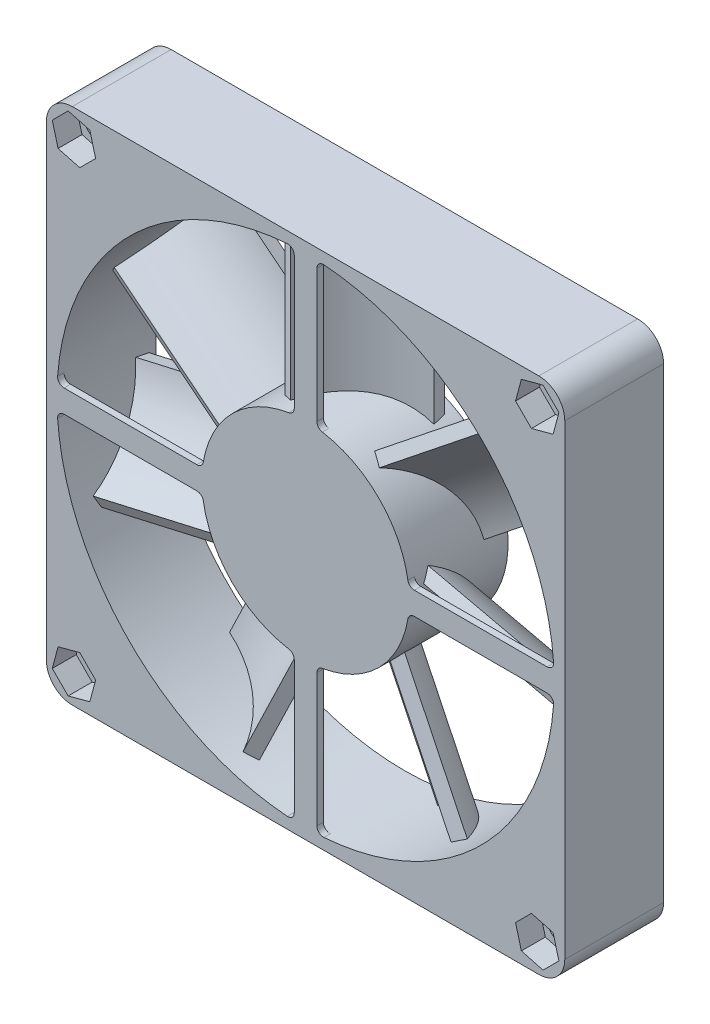
from build123d import *

# Parameters (mm, degrees)
SKETCH1_R           = 38.375
SKETCH1_R_2         = 2.11
BOSS_EXTRUDE1_DEPTH = 15.25
BOSS_EXTRUDE2_DEPTH = 1
CIRPATTERN1_COUNT   = 4
SKETCH4_R           = 16
BOSS_EXTRUDE3_DEPTH = 14.25
EXTRUDE_THIN1_DEPTH = 37
CIRPATTERN2_COUNT   = 7
CUT_EXTRUDE1_DEPTH  = 3.7
CUT_EXTRUDE2_DEPTH  = 3.7
CIRPATTERN3_COUNT   = 4


with BuildPart() as part:
    # Sketch1 → Boss-Extrude1 (new body)
    with BuildSketch(Plane.XY):
        with BuildLine():
            Line((-36, 40), (36, 40))
            ThreePointArc((36, 40), (38.828427125, 38.828427125), (40, 36))
            Line((40, 36), (40, -36))
            ThreePointArc((40, -36), (38.828427125, -38.828427125), (36, -40))
            Line((36, -40), (-36, -40))
            ThreePointArc((-36, -40), (-38.828427125, -38.828427125), (-40, -36))
            Line((-40, -36), (-40, 36))
            ThreePointArc((-40, 36), (-38.828427125, 38.828427125), (-36, 40))
        make_face()
        Circle(SKETCH1_R, mode=Mode.SUBTRACT)
        with Locations((-35.75, 35.75)):
            Circle(SKETCH1_R_2, mode=Mode.SUBTRACT)
        with Locations((-35.75, -35.75)):
            Circle(SKETCH1_R_2, mode=Mode.SUBTRACT)
        with Locations((35.75, -35.75)):
            Circle(SKETCH1_R_2, mode=Mode.SUBTRACT)
        with Locations((35.75, 35.75)):
            Circle(SKETCH1_R_2, mode=Mode.SUBTRACT)
    extrude(amount=BOSS_EXTRUDE1_DEPTH)

    # Sketch2 → Boss-Extrude2 (add)
    with BuildSketch(Plane.XY.offset(15.25)):
        with BuildLine():
            Line((-1.75, 37.27369213), (-1.75, 16.77609907))
            ThreePointArc((-1.75, 16.77609907), (-1.987843616, 16.128706108), (-2.588235294, 15.789269713))
            ThreePointArc((-2.588235294, 15.789269713), (0, -16), (2.588235294, 15.789269713))
            ThreePointArc((2.588235294, 15.789269713), (1.987843616, 16.128706108), (1.75, 16.77609907))
            Line((1.75, 16.77609907), (1.75, 37.27369213))
            ThreePointArc((1.75, 37.27369213), (2.069404156, 38.00635119), (2.823578595, 38.270981552))
            ThreePointArc((2.823578595, 38.270981552), (0, 38.375), (-2.823578595, 38.270981552))
            ThreePointArc((-2.823578595, 38.270981552), (-2.069404156, 38.00635119), (-1.75, 37.27369213))
        make_face()
    boss_extrude2 = extrude(amount=-BOSS_EXTRUDE2_DEPTH)

    # CirPattern1: Boss-Extrude2 ×4 about axis
    cirpattern1_axis = Axis((0, 0, 0), (0, 0, 1))
    for i in range(1, CIRPATTERN1_COUNT):
        add(boss_extrude2.rotate(cirpattern1_axis, i * 360 / CIRPATTERN1_COUNT))

    # Sketch4 → Boss-Extrude3 (add)
    with BuildSketch(Plane(origin=(0, 0, 14.25), x_dir=(-1, 0, 0), z_dir=(0, 0, -1))):
        with Locations(Location((0, 0, 0), (0, 0, 170.690659078))):  # turned: the seam where the file's is
            Circle(SKETCH4_R)
    extrude(amount=BOSS_EXTRUDE3_DEPTH)

    # Sketch5 → Extrude-Thin1 (add)
    with BuildSketch(Plane(origin=(0, 0, 0), x_dir=(1, 0, 0), z_dir=(0, 1, 0))):
        with BuildLine():
            ThreePointArc((-6.378336308, -12.087276377), (-0.523416229, -5.167395451), (7.814517993, -1.611598203))
            Line((7.814517993, -1.611598203), (8.153622263, -3.582640642))
            ThreePointArc((8.153622263, -3.582640642), (0.664288364, -6.77654361), (-4.59474226, -12.992147789))
            Line((-4.59474226, -12.992147789), (-6.378336308, -12.087276377))
        make_face()
    extrude_thin1 = extrude(amount=EXTRUDE_THIN1_DEPTH)

    # CirPattern2: Extrude-Thin1 ×7 about axis
    cirpattern2_axis = Axis((0, 0, 0), (0, 0, 1))
    for i in range(1, CIRPATTERN2_COUNT):
        add(extrude_thin1.rotate(cirpattern2_axis, i * 360 / CIRPATTERN2_COUNT))

    # Sketch6 → Cut-Extrude1 (cut)
    with BuildSketch(Plane(origin=(0, 0, 0), x_dir=(-1, 0, 0), z_dir=(0, 0, -1))):
        Polygon((-36.646575472, 39.096065215), (-39.096065215, 36.646575472), (-38.199489743, 33.300510257), (-34.853424528, 32.403934785), (-32.403934785, 34.853424528), (-33.300510257, 38.199489743), align=None)
    cut_extrude1 = extrude(amount=-CUT_EXTRUDE1_DEPTH, mode=Mode.SUBTRACT)

    # Sketch7 → Cut-Extrude2 (cut)
    with BuildSketch(Plane.XY.offset(15.25)):
        Polygon((36.646575472, 39.096065215), (33.300510257, 38.199489743), (32.403934785, 34.853424528), (34.853424528, 32.403934785), (38.199489743, 33.300510257), (39.096065215, 36.646575472), align=None)
    cut_extrude2 = extrude(amount=-CUT_EXTRUDE2_DEPTH, mode=Mode.SUBTRACT)

    # CirPattern3: Cut-Extrude1, Cut-Extrude2 ×4 about axis
    cirpattern3_axis = Axis((0, 0, 0), (0, 0, 1))
    add([cut_extrude1.rotate(cirpattern3_axis, i * 360 / CIRPATTERN3_COUNT) for i in range(1, CIRPATTERN3_COUNT)], mode=Mode.SUBTRACT)
    add([cut_extrude2.rotate(cirpattern3_axis, i * 360 / CIRPATTERN3_COUNT) for i in range(1, CIRPATTERN3_COUNT)], mode=Mode.SUBTRACT)


solid = part.part
